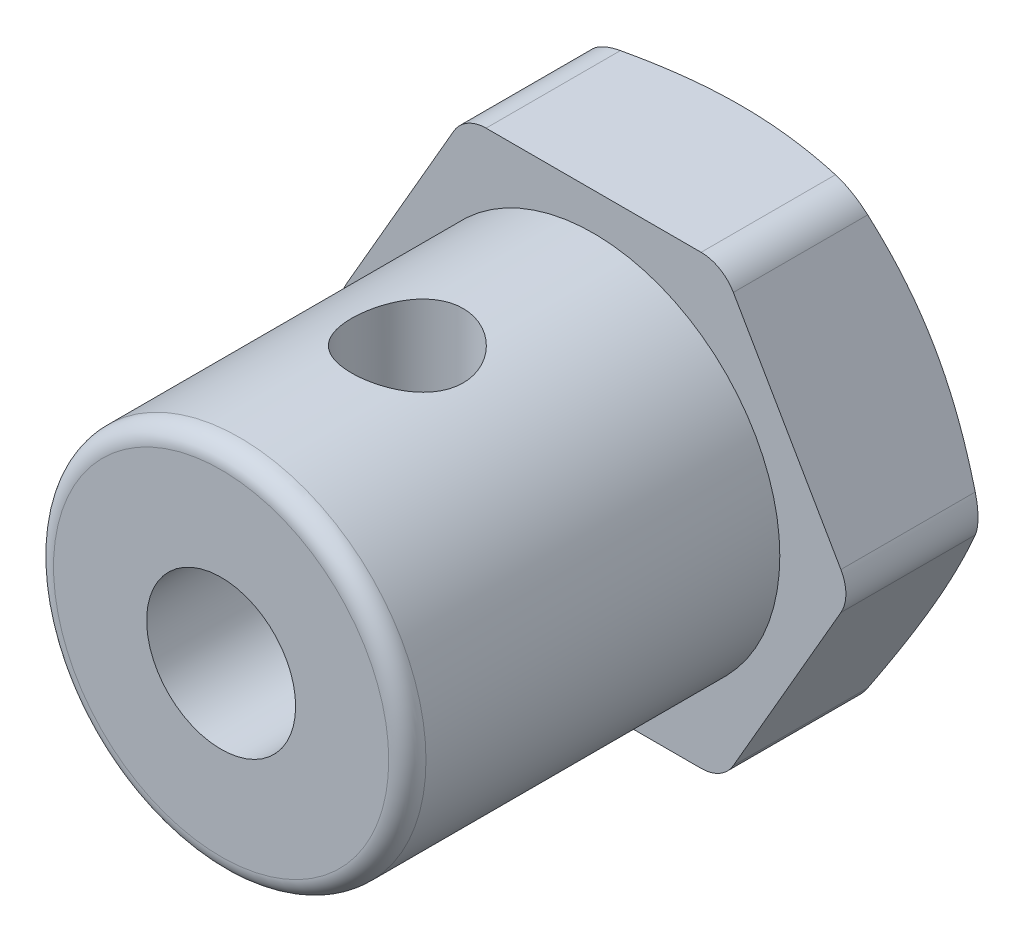
from build123d import *

# Parameters (mm, degrees)
BOSS_EXTRUDE1_DEPTH   = 4
SKETCH2_R             = 5
BOSS_EXTRUDE2_DEPTH   = 10
SKETCH3_R             = 2
CUT_EXTRUDE1_DEPTH    = 15
F_3_0MM_DOWEL_SLOT5_D = 3
FILLET1_R             = 0.5


with BuildPart() as part:
    # Sketch1 → Boss-Extrude1 (new body)
    with BuildSketch(Plane.XY):
        with BuildLine():
            Line((-2.886751346, -6), (2.886751346, -6))
            ThreePointArc((2.886751346, -6), (3.386751346, -5.866025404), (3.75277675, -5.5))
            Line((3.75277675, -5.5), (6.639528096, -0.5))
            ThreePointArc((6.639528096, -0.5), (6.773502692, 0), (6.639528096, 0.5))
            Line((6.639528096, 0.5), (3.75277675, 5.5))
            ThreePointArc((3.75277675, 5.5), (3.386751346, 5.866025404), (2.886751346, 6))
            Line((2.886751346, 6), (-2.886751346, 6))
            ThreePointArc((-2.886751346, 6), (-3.386751346, 5.866025404), (-3.75277675, 5.5))
            Line((-3.75277675, 5.5), (-6.639528096, 0.5))
            ThreePointArc((-6.639528096, 0.5), (-6.773502692, 0), (-6.639528096, -0.5))
            Line((-6.639528096, -0.5), (-3.75277675, -5.5))
            ThreePointArc((-3.75277675, -5.5), (-3.386751346, -5.866025404), (-2.886751346, -6))
        make_face()
    extrude(amount=BOSS_EXTRUDE1_DEPTH)

    # Sketch2 → Boss-Extrude2 (add)
    with BuildSketch(Plane.XY.offset(4)):
        Circle(SKETCH2_R)
    extrude(amount=BOSS_EXTRUDE2_DEPTH)

    # Sketch3 → Cut-Extrude1 (cut, through all)
    with BuildSketch(Plane.XY.offset(14)):
        Circle(SKETCH3_R)
    extrude(amount=-CUT_EXTRUDE1_DEPTH, mode=Mode.SUBTRACT)

    # Ø3.0mm Dowel Slot5 (through all)
    with Locations(Plane(origin=(0, 6, 0), x_dir=(1, 0, 0), z_dir=(0, 1, 0))):
        with Locations((0, -9)):
            Hole(F_3_0MM_DOWEL_SLOT5_D / 2)

    # Fillet1
    fillet1_edges = [part.edges().sort_by_distance(p)[0] for p in [
        (-5, 0, 14),
    ]]
    fillet(fillet1_edges, radius=FILLET1_R)

    # Sketch12 → Cut-Revolve1 (revolve, cut)
    with BuildSketch(Plane(origin=(0, 0, 0), x_dir=(1, 0, 0), z_dir=(0, 1, 0))):
        Polygon((0, 0), (0, -0.526706506), (-1.691943312, -0.526706506), (-3.449696503, 0.470605478), (-4.989422791, 0.470605478), (-6.968108857, -0.553510453), (-7.302945228, -0.553510453), (-7.302945228, 1.336347729), (0, 1.336347729), align=None)
    revolve(axis=Axis((0, 0, -3.230240026), (0, 0, 1)), mode=Mode.SUBTRACT)


solid = part.part
